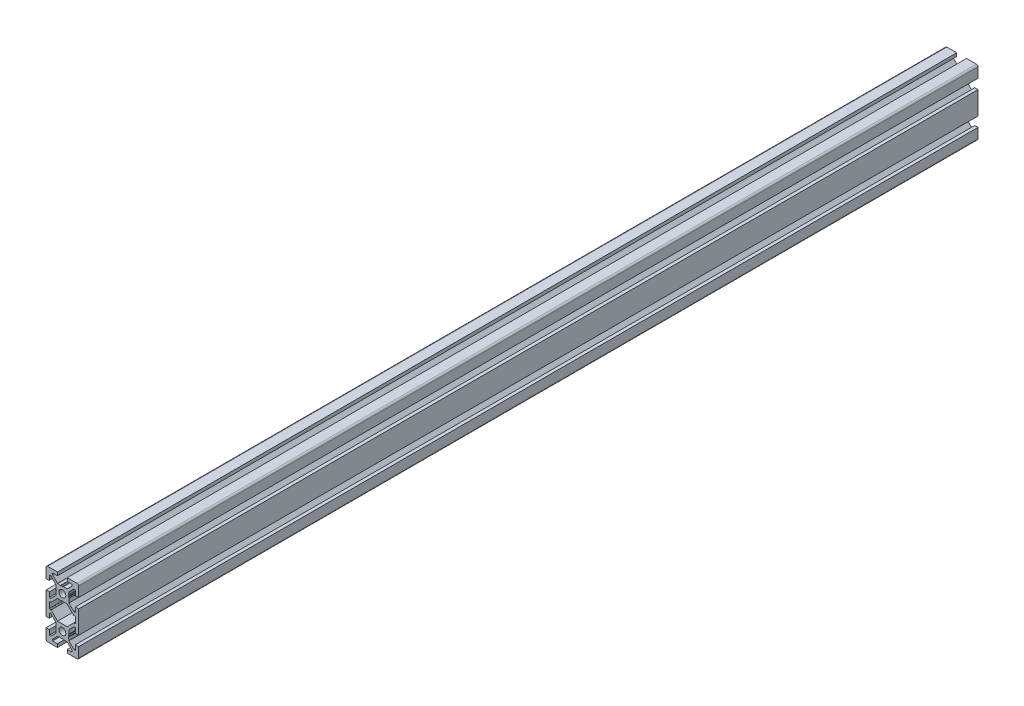
from build123d import *

# Parameters (mm, degrees)
SKETCH1_R           = 2.1
BOSS_EXTRUDE1_DEPTH = 550


with BuildPart() as part:
    # Sketch1 → Boss-Extrude1 (new body)
    with BuildSketch(Plane(origin=(0, 0, -600), x_dir=(-1, 0, 0), z_dir=(0, 0, -1))):
        with BuildLine():
            Line((10, -7), (10, 7))
            Line((10, 7), (8, 7))
            Line((8, 7), (8, 4))
            Line((8, 4), (7.060660172, 4))
            Line((7.060660172, 4), (4, 7.060660172))
            Line((4, 7.060660172), (4, 7.5))
            Line((4, 7.5), (3.750976592, 8.781114371))
            Line((3.750976592, 8.781114371), (3.933012702, 9.096410162))
            ThreePointArc((3.933012702, 9.096410162), (4, 9.346410162), (3.933012702, 9.596410162))
            Line((3.933012702, 9.596410162), (3.7, 10))
            Line((3.7, 10), (3.933012702, 10.403589838))
            ThreePointArc((3.933012702, 10.403589838), (3.982962913, 10.524180316), (4, 10.653589838))
            Line((4, 10.653589838), (4, 12.939339828))
            Line((4, 12.939339828), (7.060660172, 16))
            Line((7.060660172, 16), (8, 16))
            Line((8, 16), (8, 13))
            Line((8, 13), (10, 13))
            Line((10, 13), (10, 19))
            ThreePointArc((10, 19), (9.707106781, 19.707106781), (9, 20))
            Line((9, 20), (3, 20))
            Line((3, 20), (3, 18))
            Line((3, 18), (6, 18))
            Line((6, 18), (6, 17.060660172))
            Line((6, 17.060660172), (2.939339828, 14))
            Line((2.939339828, 14), (2.5, 14))
            Line((2.5, 14), (1.218885629, 13.750976592))
            Line((1.218885629, 13.750976592), (0.903589838, 13.933012702))
            ThreePointArc((0.903589838, 13.933012702), (0.653589838, 14), (0.403589838, 13.933012702))
            Line((0.403589838, 13.933012702), (0, 13.7))
            Line((0, 13.7), (-0.403589838, 13.933012702))
            ThreePointArc((-0.403589838, 13.933012702), (-0.524180316, 13.982962913), (-0.653589838, 14))
            Line((-0.653589838, 14), (-2.939339828, 14))
            Line((-2.939339828, 14), (-6, 17.060660172))
            Line((-6, 17.060660172), (-6, 18))
            Line((-6, 18), (-3, 18))
            Line((-3, 18), (-3, 20))
            Line((-3, 20), (-9, 20))
            ThreePointArc((-9, 20), (-9.707106781, 19.707106781), (-10, 19))
            Line((-10, 19), (-10, 13))
            Line((-10, 13), (-8, 13))
            Line((-8, 13), (-8, 16))
            Line((-8, 16), (-7.060660172, 16))
            Line((-7.060660172, 16), (-4, 12.939339828))
            Line((-4, 12.939339828), (-4, 12.5))
            Line((-4, 12.5), (-3.750976592, 11.218885629))
            Line((-3.750976592, 11.218885629), (-3.933012702, 10.903589838))
            ThreePointArc((-3.933012702, 10.903589838), (-4, 10.653589838), (-3.933012702, 10.403589838))
            Line((-3.933012702, 10.403589838), (-3.7, 10))
            Line((-3.7, 10), (-3.933012702, 9.596410162))
            ThreePointArc((-3.933012702, 9.596410162), (-3.982962913, 9.475819684), (-4, 9.346410162))
            Line((-4, 9.346410162), (-4, 7.060660172))
            Line((-4, 7.060660172), (-7.060660172, 4))
            Line((-7.060660172, 4), (-8, 4))
            Line((-8, 4), (-8, 7))
            Line((-8, 7), (-10, 7))
            Line((-10, 7), (-10, -7))
            Line((-10, -7), (-8, -7))
            Line((-8, -7), (-8, -4))
            Line((-8, -4), (-7.060660172, -4))
            Line((-7.060660172, -4), (-4, -7.060660172))
            Line((-4, -7.060660172), (-4, -9.346410162))
            ThreePointArc((-4, -9.346410162), (-3.982962913, -9.475819684), (-3.933012702, -9.596410162))
            Line((-3.933012702, -9.596410162), (-3.7, -10))
            Line((-3.7, -10), (-3.933012702, -10.403589838))
            ThreePointArc((-3.933012702, -10.403589838), (-4, -10.653589838), (-3.933012702, -10.903589838))
            Line((-3.933012702, -10.903589838), (-3.750976592, -11.218885629))
            Line((-3.750976592, -11.218885629), (-4, -12.5))
            Line((-4, -12.5), (-4, -12.939339828))
            Line((-4, -12.939339828), (-7.060660172, -16))
            Line((-7.060660172, -16), (-8, -16))
            Line((-8, -16), (-8, -13))
            Line((-8, -13), (-10, -13))
            Line((-10, -13), (-10, -19))
            ThreePointArc((-10, -19), (-9.707106781, -19.707106781), (-9, -20))
            Line((-9, -20), (-3, -20))
            Line((-3, -20), (-3, -18))
            Line((-3, -18), (-6, -18))
            Line((-6, -18), (-6, -17.060660172))
            Line((-6, -17.060660172), (-2.939339828, -14))
            Line((-2.939339828, -14), (-0.653589838, -14))
            ThreePointArc((-0.653589838, -14), (-0.524180316, -13.982962913), (-0.403589838, -13.933012702))
            Line((-0.403589838, -13.933012702), (0, -13.7))
            Line((0, -13.7), (0.403589839, -13.933012702))
            ThreePointArc((0.403589839, -13.933012702), (0.653589839, -14), (0.903589838, -13.933012702))
            Line((0.903589838, -13.933012702), (1.218885629, -13.750976592))
            Line((1.218885629, -13.750976592), (2.5, -14))
            Line((2.5, -14), (2.939339828, -14))
            Line((2.939339828, -14), (6, -17.060660172))
            Line((6, -17.060660172), (6, -18))
            Line((6, -18), (3, -18))
            Line((3, -18), (3, -20))
            Line((3, -20), (9, -20))
            ThreePointArc((9, -20), (9.707106781, -19.707106781), (10, -19))
            Line((10, -19), (10, -13))
            Line((10, -13), (8, -13))
            Line((8, -13), (8, -16))
            Line((8, -16), (7.060660172, -16))
            Line((7.060660172, -16), (4, -12.939339828))
            Line((4, -12.939339828), (4, -10.653589838))
            ThreePointArc((4, -10.653589838), (3.982962913, -10.524180316), (3.933012702, -10.403589838))
            Line((3.933012702, -10.403589838), (3.7, -10))
            Line((3.7, -10), (3.933012702, -9.596410162))
            ThreePointArc((3.933012702, -9.596410162), (4, -9.346410162), (3.933012702, -9.096410162))
            Line((3.933012702, -9.096410162), (3.750976592, -8.781114371))
            Line((3.750976592, -8.781114371), (4, -7.5))
            Line((4, -7.5), (4, -7.060660172))
            Line((4, -7.060660172), (7.060660172, -4))
            Line((7.060660172, -4), (8, -4))
            Line((8, -4), (8, -7))
            Line((8, -7), (10, -7))
        make_face()
        with Locations((0, -10)):
            Circle(SKETCH1_R, mode=Mode.SUBTRACT)
        with Locations((0, 10)):
            Circle(SKETCH1_R, mode=Mode.SUBTRACT)
        with BuildLine():
            Line((8, 1.7), (8, -1.7))
            ThreePointArc((8, -1.7), (7.912132034, -1.912132034), (7.7, -2))
            Line((7.7, -2), (7.063603897, -2))
            ThreePointArc((7.063603897, -2), (6.948798867, -2.02283614), (6.851471863, -2.087867966))
            Line((6.851471863, -2.087867966), (2.939339828, -6))
            Line((2.939339828, -6), (-2.939339828, -6))
            Line((-2.939339828, -6), (-6.851471863, -2.087867966))
            ThreePointArc((-6.851471863, -2.087867966), (-6.948798867, -2.02283614), (-7.063603897, -2))
            Line((-7.063603897, -2), (-7.7, -2))
            ThreePointArc((-7.7, -2), (-7.912132034, -1.912132034), (-8, -1.7))
            Line((-8, -1.7), (-8, 1.7))
            ThreePointArc((-8, 1.7), (-7.912132034, 1.912132034), (-7.7, 2))
            Line((-7.7, 2), (-7.063603897, 2))
            ThreePointArc((-7.063603897, 2), (-6.948798867, 2.02283614), (-6.851471863, 2.087867966))
            Line((-6.851471863, 2.087867966), (-2.939339828, 6))
            Line((-2.939339828, 6), (2.939339828, 6))
            Line((2.939339828, 6), (6.851471863, 2.087867966))
            ThreePointArc((6.851471863, 2.087867966), (6.948798867, 2.02283614), (7.063603897, 2))
            Line((7.063603897, 2), (7.7, 2))
            ThreePointArc((7.7, 2), (7.912132034, 1.912132034), (8, 1.7))
        make_face(mode=Mode.SUBTRACT)
    extrude(amount=-BOSS_EXTRUDE1_DEPTH)


solid = part.part
